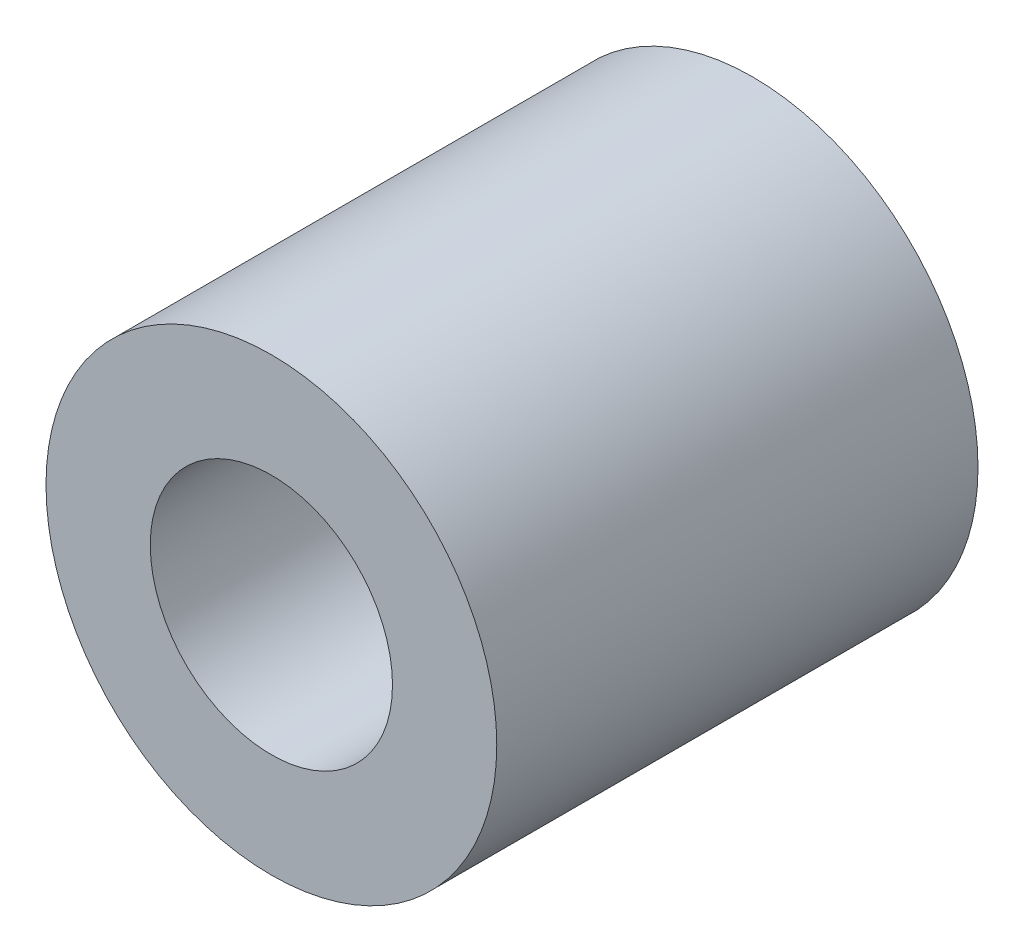
from build123d import *

# Parameters (mm, degrees)
SKETCH1_R           = 1.405
BOSS_EXTRUDE1_DEPTH = 3
SKETCH2_R           = 0.755
CUT_EXTRUDE1_DEPTH  = 2.8


with BuildPart() as part:
    # Sketch1 → Boss-Extrude1 (new body)
    with BuildSketch(Plane.XY):
        Circle(SKETCH1_R)
    extrude(amount=BOSS_EXTRUDE1_DEPTH)

    # Sketch2 → Cut-Extrude1 (cut)
    with BuildSketch(Plane.XY.offset(3)):
        Circle(SKETCH2_R)
    extrude(amount=-CUT_EXTRUDE1_DEPTH, mode=Mode.SUBTRACT)


solid = part.part
